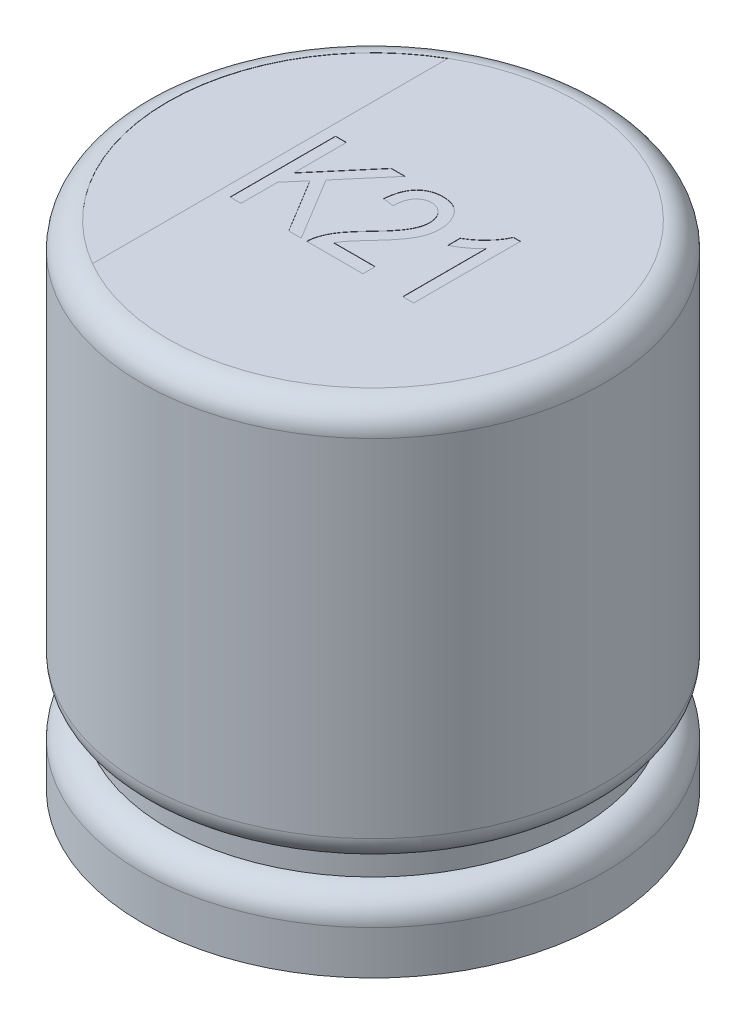
from build123d import *

# Parameters (mm, degrees)
SKETCH1_R           = 9
BOSS_EXTRUDE1_DEPTH = 19.2
FILLET1_R           = 1
CUT_EXTRUDE1_DEPTH  = 0.01
CUT_EXTRUDE2_DEPTH  = 0.01


with BuildPart() as part:
    # Sketch1 → Boss-Extrude1 (new body)
    with BuildSketch(Plane(origin=(0, 0, 0), x_dir=(1, 0, 0), z_dir=(0, 1, 0))):
        Circle(SKETCH1_R)
    extrude(amount=BOSS_EXTRUDE1_DEPTH)

    # Fillet1
    fillet1_edges = [part.edges().sort_by_distance(p)[0] for p in [
        (-9, 19.2, 0),
    ]]
    fillet(fillet1_edges, radius=FILLET1_R)

    # Sketch2 → Cut-Revolve1 (revolve, cut)
    with BuildSketch(Plane.XY):
        with BuildLine():
            Line((-9, 4.7), (-9, 1.7))
            ThreePointArc((-9, 1.7), (-8.707106781, 2.407106781), (-8, 2.7))
            Line((-8, 2.7), (-8, 3.7))
            ThreePointArc((-8, 3.7), (-8.707106781, 3.992893219), (-9, 4.7))
        make_face()
    revolve(axis=Axis((0, -0.75, 0), (0, 1, 0)), mode=Mode.SUBTRACT)

    # Sketch3 → Cut-Extrude1 (cut)
    with BuildSketch(Plane(origin=(0, 19.2, 0), x_dir=(1, 0, 0), z_dir=(0, 1, 0))):
        with BuildLine():
            Line((-4, 6.92820323), (-4, -6.92820323))
            ThreePointArc((-4, -6.92820323), (-8, 0), (-4, 6.92820323))
        make_face()
    extrude(amount=-CUT_EXTRUDE1_DEPTH, mode=Mode.SUBTRACT)

    # Sketch4 → Cut-Extrude2 (cut)
    with BuildSketch(Plane(origin=(0, 19.2, 0), x_dir=(1, 0, 0), z_dir=(0, 1, 0))):
        Polygon((-3.568517869, -2), (-3.568517869, 2.109309896), (-3.141576581, 2.109309896), (-3.141576581, 0.062159775), (-1.398788902, 2.109309896), (-0.855105856, 2.109309896), (-2.27435209, 0.44240436), (-0.793399498, -2), (-1.283714883, -2), (-2.561203268, 0.105521), (-3.141576581, -0.575750547), (-3.141576581, -2), align=None)
        with BuildLine():
            Line((1.608145247, -1.519691051), (1.608145247, -2))
            Line((1.608145247, -2), (-0.579928854, -2))
            add(Edge.make_bspline(
                [(-0.579928854, -2), (-0.580030163, -1.974973894), (-0.580235417, -1.924270595), (-0.573411363, -1.84696894), (-0.559390758, -1.767795767), (-0.541487877, -1.685694894), (-0.516103543, -1.601746123), (-0.485028409, -1.515541552), (-0.448362485, -1.427295796), (-0.405430031, -1.336486232), (-0.355261299, -1.242241802), (-0.29472218, -1.144956808), (-0.22514772, -1.042886175), (-0.146445909, -0.936652158), (-0.057077523, -0.827262261), (0.040304888, -0.713092602), (0.147091103, -0.594380978), (0.223123115, -0.515484132), (0.262279546, -0.474852313)],
                knots=[0, 0, 0, 0, 7.5053e-05, 0.000152058, 0.000232392, 0.000316145, 0.000404002, 0.000495264, 0.000590967, 0.000690561, 0.000796512, 0.000911068, 0.001034111, 0.001167032, 0.001307551, 0.001457781, 0.001617197, 0.001786472, 0.001786472, 0.001786472, 0.001786472], degree=3))
            add(Edge.make_bspline(
                [(0.262279546, -0.474852313), (0.307783709, -0.427786045), (0.395398434, -0.337163605), (0.518707793, -0.20335402), (0.63074673, -0.078979672), (0.729276779, 0.038208492), (0.81604721, 0.146614403), (0.891931027, 0.246083065), (0.953301744, 0.338871858), (1.019564668, 0.4480512), (1.082736953, 0.578027477), (1.138584831, 0.729535393), (1.17466971, 0.875998462), (1.179068277, 0.972558443), (1.181203959, 1.019442194)],
                knots=[0, 0, 0, 0, 0.000196392, 0.000378137, 0.000545859, 0.000698537, 0.000837361, 0.000962441, 0.001073684, 0.001170929, 0.001345461, 0.001506112, 0.00165499, 0.001795499, 0.001795499, 0.001795499, 0.001795499], degree=3))
            add(Edge.make_bspline(
                [(1.181203959, 1.019442194), (1.180906167, 1.045325757), (1.180324549, 1.095879063), (1.17044076, 1.169706759), (1.156345175, 1.239928333), (1.137734826, 1.307051289), (1.111347496, 1.369973118), (1.079731025, 1.429130374), (1.042696817, 1.484790988), (1.00043516, 1.536137563), (0.953830167, 1.582458591), (0.904715044, 1.624072216), (0.851812101, 1.657752353), (0.79729566, 1.687071594), (0.739323506, 1.708320386), (0.679116382, 1.72451746), (0.616117255, 1.733650108), (0.573340408, 1.735033988), (0.551632333, 1.735736269)],
                knots=[0, 0, 0, 0, 7.759e-05, 0.000151542, 0.000223007, 0.000292419, 0.000360091, 0.000427242, 0.000493386, 0.00056033, 0.000626369, 0.000690322, 0.000753001, 0.00081417, 0.000875656, 0.00093775, 0.001000959, 0.001066087, 0.001066087, 0.001066087, 0.001066087], degree=3))
            add(Edge.make_bspline(
                [(0.551632333, 1.735736269), (0.528226771, 1.735245249), (0.48253804, 1.734286754), (0.415943734, 1.722375263), (0.352134158, 1.706440041), (0.291433109, 1.681725902), (0.234284586, 1.650068594), (0.179865337, 1.611963), (0.129240549, 1.566688844), (0.081390427, 1.51520671), (0.0394437, 1.456500761), (0.00093045, 1.392974506), (-0.029397111, 1.321936977), (-0.055184289, 1.245578615), (-0.075379706, 1.163009336), (-0.08887873, 1.074540543), (-0.098778232, 0.980193805), (-0.099334188, 0.9152366), (-0.099619905, 0.881853693)],
                knots=[0, 0, 0, 0, 7.0124e-05, 0.000136886, 0.000202418, 0.000267144, 0.000332829, 0.000398068, 0.000466002, 0.00053623, 0.00060845, 0.0006821, 0.000758639, 0.000839594, 0.000923728, 0.001013247, 0.00110792, 0.001208016, 0.001208016, 0.001208016, 0.001208016], degree=3))
            Line((-0.099619905, 0.881853693), (-0.526561193, 0.935221354))
            add(Edge.make_bspline(
                [(-0.526561193, 0.935221354), (-0.522161355, 0.984764496), (-0.51362547, 1.080880441), (-0.491229682, 1.220023192), (-0.460151497, 1.349122738), (-0.423259749, 1.469467004), (-0.37684568, 1.579562455), (-0.32495328, 1.681412702), (-0.263448356, 1.772803706), (-0.194860218, 1.854865311), (-0.119763265, 1.927670687), (-0.038580752, 1.990514656), (0.048577079, 2.043490936), (0.140714878, 2.088035445), (0.239737182, 2.121299299), (0.343867527, 2.145441457), (0.453952846, 2.159744427), (0.529075899, 2.161685405), (0.567475857, 2.162677557)],
                knots=[0, 0, 0, 0, 0.000149186, 0.000289427, 0.000422308, 0.000547317, 0.00066656, 0.000780315, 0.000889708, 0.000996261, 0.001100641, 0.001202885, 0.001303565, 0.001406135, 0.001509242, 0.001616244, 0.001726397, 0.001841579, 0.001841579, 0.001841579, 0.001841579], degree=3))
            add(Edge.make_bspline(
                [(0.567475857, 2.162677557), (0.608936701, 2.161460519), (0.689667848, 2.159090743), (0.807193372, 2.143475809), (0.916807406, 2.115932118), (1.018999557, 2.077604645), (1.112542526, 2.027147582), (1.198957878, 1.966622956), (1.276803441, 1.894190881), (1.346078887, 1.811773402), (1.407300961, 1.722793837), (1.460721222, 1.629751813), (1.507059009, 1.534189022), (1.543273299, 1.435042114), (1.573516087, 1.33364172), (1.592515267, 1.22845074), (1.605890551, 1.120682885), (1.607389437, 1.047836248), (1.608145247, 1.011103497)],
                knots=[0, 0, 0, 0, 0.000124384, 0.000242196, 0.000354845, 0.000462789, 0.000568739, 0.00067285, 0.000778475, 0.00088674, 0.000995223, 0.001102066, 0.001208364, 0.001313378, 0.001418413, 0.00152537, 0.001633664, 0.001743813, 0.001743813, 0.001743813, 0.001743813], degree=3))
            add(Edge.make_bspline(
                [(1.608145247, 1.011103497), (1.607433131, 0.978008896), (1.606018176, 0.912250864), (1.596813778, 0.814136149), (1.580566309, 0.717340512), (1.559469686, 0.620933232), (1.529533435, 0.526407037), (1.495644001, 0.432260621), (1.454538746, 0.339556084), (1.406012971, 0.24648385), (1.349195592, 0.149750322), (1.281109579, 0.047590004), (1.203017594, -0.062727889), (1.111747658, -0.179237735), (1.011722256, -0.305290035), (0.898522434, -0.437708632), (0.774356786, -0.577661228), (0.686878474, -0.672623554), (0.641690261, -0.721677745)],
                knots=[0, 0, 0, 0, 9.9287e-05, 0.00019728, 0.000295297, 0.000393613, 0.000493053, 0.000592508, 0.000693685, 0.000796994, 0.000907257, 0.001030065, 0.001165193, 0.001312635, 0.001473988, 0.001647918, 0.001835167, 0.002035249, 0.002035249, 0.002035249, 0.002035249], degree=3))
            add(Edge.make_bspline(
                [(0.641690261, -0.721677745), (0.613003238, -0.752199341), (0.558180033, -0.810528561), (0.480543807, -0.894931672), (0.410876198, -0.971712133), (0.347660418, -1.039789018), (0.294021708, -1.101451752), (0.24751759, -1.155071433), (0.209520156, -1.201308971), (0.152573929, -1.273997274), (0.080749983, -1.376414434), (0.031128398, -1.472967089), (0.007115417, -1.519691051)],
                knots=[0, 0, 0, 0, 0.00012566, 0.000240146, 0.000344029, 0.000436694, 0.000518825, 0.000589192, 0.000649623, 0.000698331, 0.000866252, 0.00102371, 0.00102371, 0.00102371, 0.00102371], degree=3))
            Line((0.007115417, -1.519691051), (1.608145247, -1.519691051))
        make_face()
        with BuildLine():
            Line((3.582748703, -2), (3.155807415, -2))
            Line((3.155807415, -2), (3.155807415, 1.25542732))
            add(Edge.make_bspline(
                [(3.155807415, 1.25542732), (3.129587392, 1.225245825), (3.075246421, 1.162694706), (2.980913282, 1.0737383), (2.87578942, 0.982006095), (2.759403349, 0.892993451), (2.640815205, 0.807733741), (2.523687376, 0.732746343), (2.412409759, 0.667501655), (2.337758183, 0.63203815), (2.301924839, 0.615015388)],
                knots=[0, 0, 0, 0, 0.000119871, 0.000248434, 0.000388536, 0.000538317, 0.000687792, 0.000826575, 0.000955448, 0.001074411, 0.001074411, 0.001074411, 0.001074411], degree=3))
            Line((2.301924839, 0.615015388), (2.301924839, 1.095324337))
            add(Edge.make_bspline(
                [(2.301924839, 1.095324337), (2.359511914, 1.12998243), (2.474192959, 1.199001848), (2.634876111, 1.318565767), (2.786671409, 1.447615361), (2.925041729, 1.587502781), (3.048937153, 1.731705768), (3.155279444, 1.875620528), (3.242473386, 2.017717985), (3.285244807, 2.115464643), (3.305903962, 2.162677557)],
                knots=[0, 0, 0, 0, 0.000201529, 0.000401333, 0.000600042, 0.00079875, 0.000990948, 0.001169906, 0.001335222, 0.001489675, 0.001489675, 0.001489675, 0.001489675], degree=3))
            Line((3.305903962, 2.162677557), (3.582748703, 2.162677557))
            Line((3.582748703, 2.162677557), (3.582748703, -2))
        make_face()
    extrude(amount=-CUT_EXTRUDE2_DEPTH, mode=Mode.SUBTRACT)


solid = part.part
